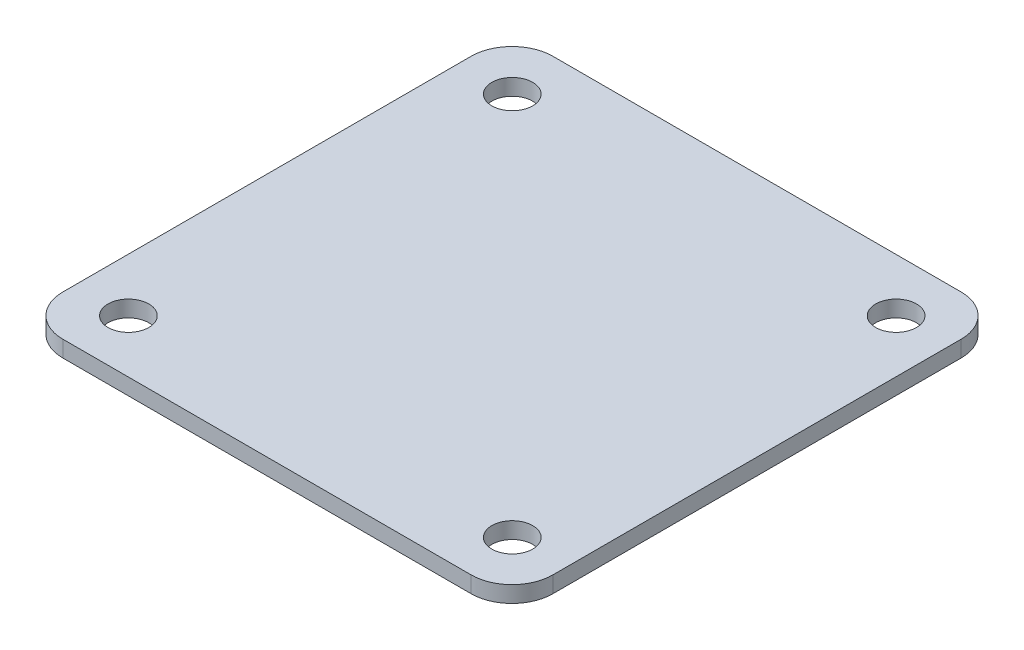
from build123d import *

# Parameters (mm, degrees)
SKETCH1_W           = 60
SKETCH1_H           = 60
SKETCH1_R           = 2.5
BOSS_EXTRUDE1_DEPTH = 2
FILLET1_R           = 5


with BuildPart() as part:
    # Sketch1 → Boss-Extrude1 (new body)
    with BuildSketch(Plane(origin=(0, 0, 0), x_dir=(1, 0, 0), z_dir=(0, 1, 0))):
        with Locations((-3.72837965, -11.916859122)):
            Rectangle(SKETCH1_W, SKETCH1_H)
        with Locations((19.802535265, 11.583140878)):
            Circle(SKETCH1_R, mode=Mode.SUBTRACT)
        with Locations((-27.197464735, 11.583140878)):
            Circle(SKETCH1_R, mode=Mode.SUBTRACT)
        with Locations((19.802535265, -35.416859122)):
            Circle(SKETCH1_R, mode=Mode.SUBTRACT)
        with Locations((-27.197464735, -35.416859122)):
            Circle(SKETCH1_R, mode=Mode.SUBTRACT)
    extrude(amount=BOSS_EXTRUDE1_DEPTH)

    # Fillet1
    fillet1_edges = [part.edges().sort_by_distance(p)[0] for p in [
        (-33.72837965, 1, -18.083140878),
        (26.27162035, 1, -18.083140878),
        (26.27162035, 1, 41.916859122),
        (-33.72837965, 1, 41.916859122),
    ]]
    fillet(fillet1_edges, radius=FILLET1_R)


solid = part.part
